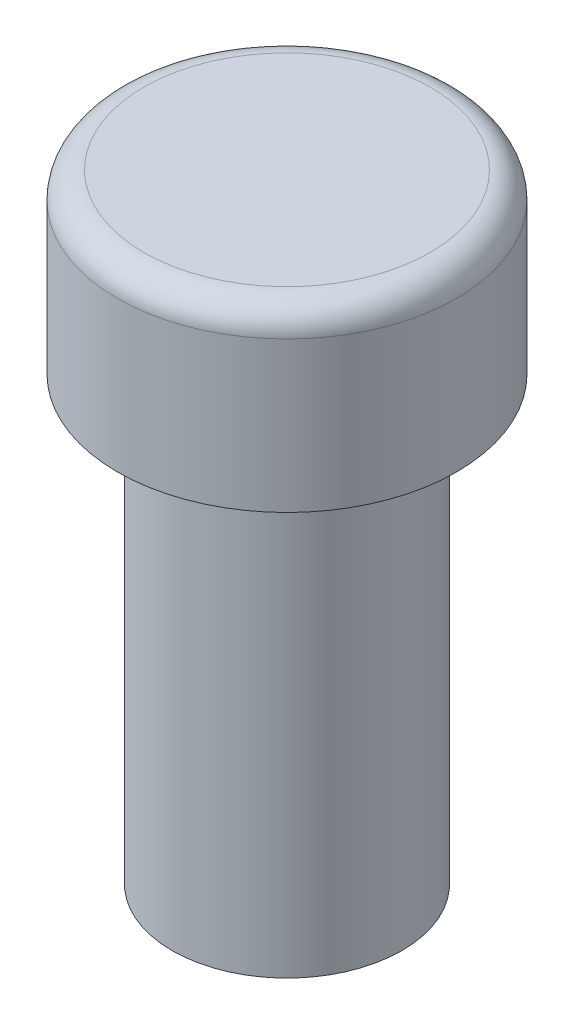
from build123d import *

# Parameters (mm, degrees)
SKETCH1_R           = 3.25
BOSS_EXTRUDE1_DEPTH = 12.5
SKETCH2_R           = 1.75
CUT_EXTRUDE1_DEPTH  = 2.5
SKETCH6_R           = 4.8
BOSS_EXTRUDE2_DEPTH = 5
FILLET1_R           = 0.75


with BuildPart() as part:
    # Sketch1 → Boss-Extrude1 (new body)
    with BuildSketch(Plane(origin=(0, 0, 0), x_dir=(1, 0, 0), z_dir=(0, 1, 0))):
        Circle(SKETCH1_R)
    extrude(amount=BOSS_EXTRUDE1_DEPTH)

    # Sketch2 → Cut-Extrude1 (cut)
    with BuildSketch(Plane.XZ):
        Circle(SKETCH2_R)
    extrude(amount=-CUT_EXTRUDE1_DEPTH, mode=Mode.SUBTRACT)

    # Sketch6 → Boss-Extrude2 (add)
    with BuildSketch(Plane(origin=(0, 12.5, 0), x_dir=(1, 0, 0), z_dir=(0, 1, 0))):
        Circle(SKETCH6_R)
    extrude(amount=BOSS_EXTRUDE2_DEPTH)

    # Fillet1
    fillet1_edges = [part.edges().sort_by_distance(p)[0] for p in [
        (-4.8, 17.5, 0),
    ]]
    fillet(fillet1_edges, radius=FILLET1_R)


solid = part.part
